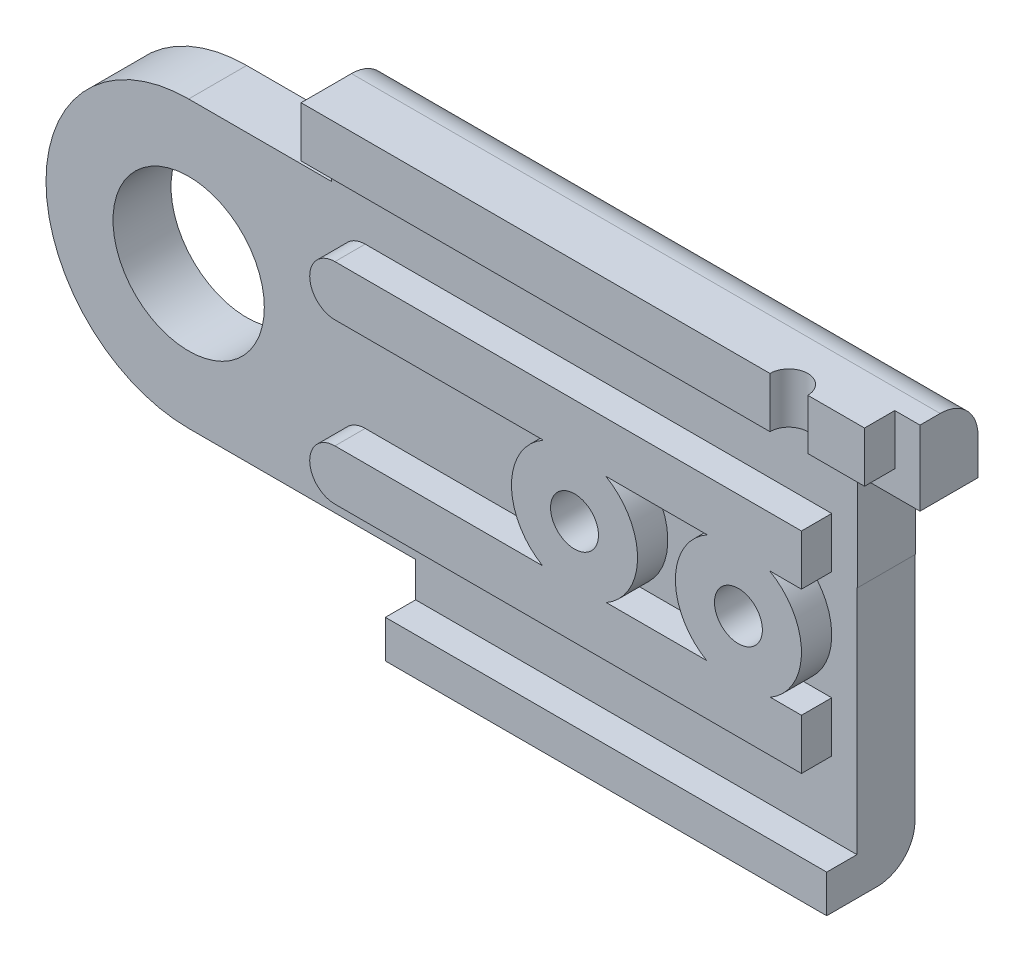
from build123d import *

# Parameters (mm, degrees)
BOSS_EXTRUDE1_DEPTH  = 2
BOSS_EXTRUDE6_DEPTH  = 4.5
CUT_EXTRUDE6_DEPTH   = 4.5
BOSS_EXTRUDE14_DEPTH = 2.3
SKETCH32_R           = 3
CUT_EXTRUDE7_DEPTH   = 2.3
SKETCH33_W           = 22.343119157
SKETCH33_H           = 2
SKETCH33_W_2         = 17.499973406
SKETCH33_H_2         = 1.5
BOSS_EXTRUDE15_DEPTH = 1.2
SKETCH35_W           = 5.479645996
SKETCH35_H           = 3.871139505
CUT_EXTRUDE8_DEPTH   = 2.4
SKETCH36_W           = 3.7
SKETCH36_H           = 1.871139505
CUT_EXTRUDE9_DEPTH   = 4.4
SKETCH37_R           = 3.9
BOSS_EXTRUDE16_DEPTH = 4.4
CUT_EXTRUDE10_DEPTH  = 7.4
SKETCH43_R           = 2.5
BOSS_EXTRUDE17_DEPTH = 1.2
SKETCH44_R           = 0.95
CUT_EXTRUDE11_DEPTH  = 11
SKETCH45_R           = 2
CUT_EXTRUDE12_DEPTH  = 4.5
SKETCH49_R           = 0.75
CUT_EXTRUDE13_DEPTH  = 3
SKETCH51_W           = 3
SKETCH51_H           = 3.965585241
CUT_EXTRUDE14_DEPTH  = 6.8
FILLET1_R            = 1.5
FILLET3_R            = 1


with BuildPart() as part:
    # Sketch3 → Boss-Extrude1 (new body)
    with BuildSketch(Plane.XY):
        with BuildLine():
            Line((8, 0), (9, -2.543145751))
            Line((9, -2.543145751), (9, -7.043145751))
            Line((9, -7.043145751), (26.499973406, -7.043145751))
            Line((26.499973406, -7.043145751), (30.050225938, -4.992893219))
            ThreePointArc((30.050225938, -4.992893219), (41.467130134, -2.721929777), (34.999973406, 6.956854249))
            Line((34.999973406, 6.956854249), (31.999973406, 7.456854249))
            Line((31.999973406, 7.456854249), (5.656854249, 7.456854249))
            Line((5.656854249, 7.456854249), (5.656854249, 5.656854249))
            ThreePointArc((5.656854249, 5.656854249), (7.39103626, 3.061467459), (8, 0))
        make_face()
    extrude(amount=BOSS_EXTRUDE1_DEPTH)

    # Sketch22 → Boss-Extrude6 (add)
    with BuildSketch(Plane.XY.offset(2)):
        with BuildLine():
            Line((5.656854249, 7.456854249), (26.499973406, 7.456854249))
            Line((26.499973406, 7.456854249), (31.999973406, 7.456854249))
            Line((31.999973406, 7.456854249), (31.999973406, 2.128860495))
            Line((31.999973406, 2.128860495), (28.275099672, 2.128860495))
            Line((28.275099672, 2.128860495), (28.275099672, -6.018019485))
            Line((28.275099672, -6.018019485), (26.499973406, -7.043145751))
            Line((26.499973406, -7.043145751), (9, -7.043145751))
            Line((9, -7.043145751), (9, -2.543145751))
            Line((9, -2.543145751), (8, 0))
            ThreePointArc((8, 0), (7.39103626, 3.061467459), (5.656854249, 5.656854249))
            Line((5.656854249, 5.656854249), (5.656854249, 7.456854249))
        make_face()
    extrude(amount=BOSS_EXTRUDE6_DEPTH)

    # Sketch26 → Cut-Extrude6 (cut)
    with BuildSketch(Plane.XY.offset(2)):
        Polygon((18.098080448, 5.3), (2.530052458, 5.3), (2.530052458, 4), (18.098080448, 4), (31.999973406, 4), (31.999973406, 5.3), align=None)
    extrude(amount=CUT_EXTRUDE6_DEPTH, mode=Mode.SUBTRACT)


with BuildPart() as body_2:
    # Sketch31 → Boss-Extrude14 (new body)
    with BuildSketch(Plane.XY.offset(6.5)):
        with BuildLine():
            Line((2.432688066, 5.656854249), (0, 5.656854249))
            ThreePointArc((0, 5.656854249), (-5.656854249, 0), (0, -5.656854249))
            Line((0, -5.656854249), (9, -5.656854249))
            Line((9, -5.656854249), (9, -7.043145751))
            Line((9, -7.043145751), (9, -8.543145751))
            Line((9, -8.543145751), (26.499973406, -8.543145751))
            Line((26.499973406, -8.543145751), (26.499973406, -7.043145751))
            Line((26.499973406, -7.043145751), (26.499973406, 2.128860495))
            Line((26.499973406, 2.128860495), (28.275099672, 2.128860495))
            Line((28.275099672, 2.128860495), (31.999973406, 2.128860495))
            Line((31.999973406, 2.128860495), (31.999973406, 7.456854249))
            Line((31.999973406, 7.456854249), (31.999973406, 8.956854249))
            Line((31.999973406, 8.956854249), (5.656854249, 8.956854249))
            Line((5.656854249, 8.956854249), (5.656854249, 7.456854249))
            Line((5.656854249, 7.456854249), (5.656854249, 5.656854249))
            Line((5.656854249, 5.656854249), (2.432688066, 5.656854249))
        make_face()
    extrude(amount=BOSS_EXTRUDE14_DEPTH)

    # Sketch32 → Cut-Extrude7 (cut)
    with BuildSketch(Plane.XY.offset(8.8)):
        Circle(SKETCH32_R)
    extrude(amount=-CUT_EXTRUDE7_DEPTH, mode=Mode.SUBTRACT)

    # Sketch33 → Boss-Extrude15 (add)
    with BuildSketch(Plane.XY.offset(8.8)):
        with Locations((16.828413828, 7.956854249)):
            Rectangle(SKETCH33_W, SKETCH33_H)
        with Locations((17.749986703, -7.793145751)):
            Rectangle(SKETCH33_W_2, SKETCH33_H_2)
        with BuildLine():
            Line((7, -4.156854249), (25.499973406, -4.156854249))
            Line((25.499973406, -4.156854249), (25.499973406, -2.156854249))
            Line((25.499973406, -2.156854249), (7, -2.156854249))
            ThreePointArc((7, -2.156854249), (6, -3.156854249), (7, -4.156854249))
        make_face()
        with BuildLine():
            Line((25.499973406, 2.172006245), (7, 2.172006245))
            ThreePointArc((7, 2.172006245), (6, 3.172006245), (7, 4.172006245))
            Line((7, 4.172006245), (25.499973406, 4.172006245))
            Line((25.499973406, 4.172006245), (25.499973406, 2.172006245))
        make_face()
    extrude(amount=BOSS_EXTRUDE15_DEPTH)


with BuildPart() as cut_extrude8_tool:
    # Sketch35 → Cut-Extrude8 (new body)
    with BuildSketch(Plane.XY.offset(8.8)):
        with Locations((29.260150408, 4.064430247)):
            Rectangle(SKETCH35_W, SKETCH35_H)
    extrude(amount=-CUT_EXTRUDE8_DEPTH)


with BuildPart() as part_1:
    add(part.part)

    # Cut-Extrude8: cut by cut_extrude8_tool
    add(cut_extrude8_tool.part, mode=Mode.SUBTRACT)

    # Sketch36 → Cut-Extrude9 (cut)
    with BuildSketch(Plane.XY.offset(6.4)):
        with Locations((30.149973406, 3.064430247)):
            Rectangle(SKETCH36_W, SKETCH36_H)
    extrude(amount=-CUT_EXTRUDE9_DEPTH, mode=Mode.SUBTRACT)

    # Sketch37 → Boss-Extrude16 (add)
    with BuildSketch(Plane.XY.offset(2)):
        with Locations((34.999973406, -0.043145751)):
            Circle(SKETCH37_R)
    extrude(amount=BOSS_EXTRUDE16_DEPTH)

    # Sketch39 → Cut-Extrude10 (cut, through all)
    with BuildSketch(Plane.XY.offset(6.4)):
        with BuildLine():
            Line((33.999973406, 0.936650147), (33.999973406, -1.022941648))
            ThreePointArc((33.999973406, -1.022941648), (36.399973406, -0.043145751), (33.999973406, 0.936650147))
        make_face()
    extrude(amount=-CUT_EXTRUDE10_DEPTH, mode=Mode.SUBTRACT)


with BuildPart() as body_2_1:
    add(body_2.part)

    # Cut-Extrude8: cut by cut_extrude8_tool
    add(cut_extrude8_tool.part, mode=Mode.SUBTRACT)

    # Sketch43 → Boss-Extrude17 (add)
    with BuildSketch(Plane.XY.offset(8.8)):
        with Locations((16.5, 0)):
            Circle(SKETCH43_R)
        with Locations((23, 0)):
            Circle(SKETCH43_R)
    extrude(amount=BOSS_EXTRUDE17_DEPTH)


with BuildPart() as cut_extrude11_tool:
    # Sketch44 → Cut-Extrude11 (new body, through all)
    with BuildSketch(Plane.XY.offset(10)):
        with Locations((16.5, 0)):
            Circle(SKETCH44_R)
        with Locations((23, 0)):
            Circle(SKETCH44_R)
    extrude(amount=-CUT_EXTRUDE11_DEPTH)


with BuildPart() as part_2:
    add(part_1.part)

    # Cut-Extrude11: cut by cut_extrude11_tool
    add(cut_extrude11_tool.part, mode=Mode.SUBTRACT)

    # Sketch45 → Cut-Extrude12 (cut)
    with BuildSketch(Plane(origin=(0, 0, 0), x_dir=(-1, 0, 0), z_dir=(0, 0, -1))):
        with Locations((-16.5, 0)):
            Circle(SKETCH45_R)
        with Locations((-23, 0)):
            Circle(SKETCH45_R)
    extrude(amount=-CUT_EXTRUDE12_DEPTH, mode=Mode.SUBTRACT)


with BuildPart() as body_2_2:
    add(body_2_1.part)

    # Cut-Extrude11: cut by cut_extrude11_tool
    add(cut_extrude11_tool.part, mode=Mode.SUBTRACT)

    # Sketch49 → Cut-Extrude13 (cut)
    with BuildSketch(Plane.XZ.offset(-6.956854249)):
        with Locations((24.999973406, 10)):
            Circle(SKETCH49_R)
    extrude(amount=-CUT_EXTRUDE13_DEPTH, mode=Mode.SUBTRACT)


with BuildPart() as cut_extrude14_tool:
    # Sketch51 → Cut-Extrude14 (new body)
    with BuildSketch(Plane.XY.offset(8.8)):
        with Locations((30.499973406, 6.974061629)):
            Rectangle(SKETCH51_W, SKETCH51_H)
    extrude(amount=-CUT_EXTRUDE14_DEPTH)


with BuildPart() as part_3:
    add(part_2.part)

    # Cut-Extrude14: cut by cut_extrude14_tool
    add(cut_extrude14_tool.part, mode=Mode.SUBTRACT)

    # Fillet3
    fillet3_edges = [part_3.edges().sort_by_distance(p)[0] for p in [
        (28.275099672, -6.018019485, 4.25),
        (28.999973406, 7.456854249, 4.25),
        (9, -7.043145751, 3.25),
        (5.656854249, 7.456854249, 3.25),
        (17.749986703, -7.043145751, 0),
        (18.828413828, 7.456854249, 0),
    ]]
    fillet(fillet3_edges, radius=FILLET3_R)


with BuildPart() as body_2_3:
    add(body_2_2.part)

    # Cut-Extrude14: cut by cut_extrude14_tool
    add(cut_extrude14_tool.part, mode=Mode.SUBTRACT)

    # Fillet1
    fillet1_edges = [body_2_3.edges().sort_by_distance(p)[0] for p in [
        (17.328413828, 8.956854249, 6.5),
        (17.749986703, -8.543145751, 6.5),
    ]]
    fillet(fillet1_edges, radius=FILLET1_R)


solid = body_2_3.part
